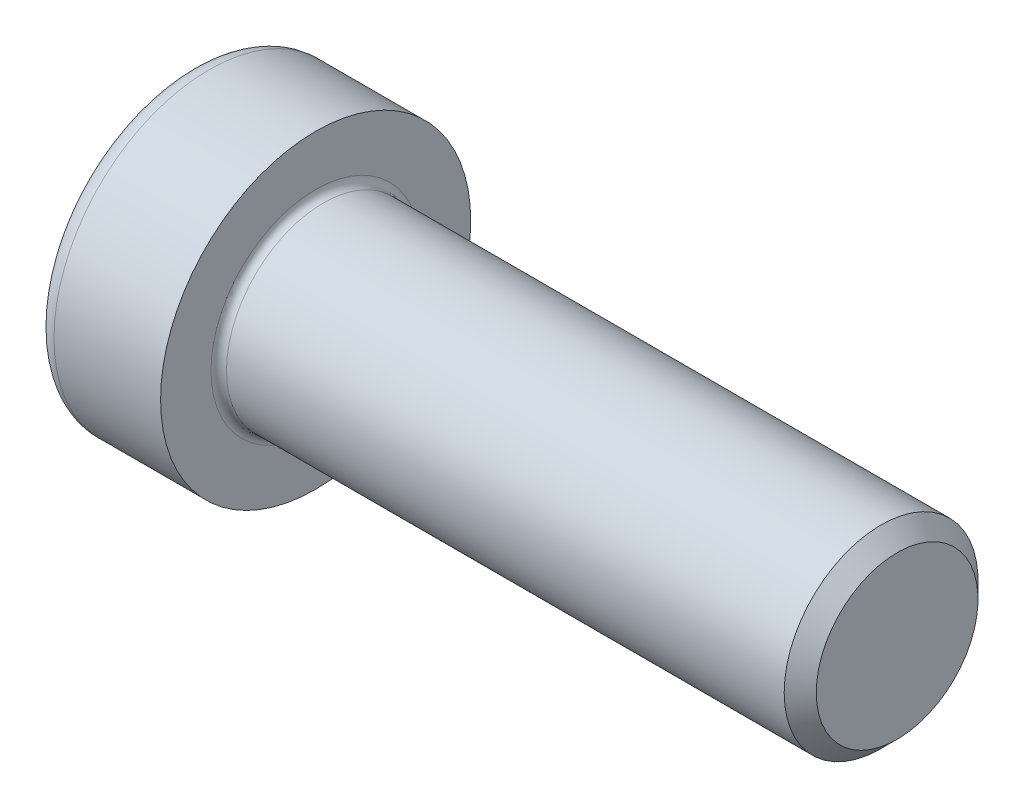
from build123d import *

# Parameters (mm, degrees)
FILLET1_R   = 0.4
FILLET2_R   = 1
HEX_2_DEPTH = 3.65


with BuildPart() as part:
    # BodySke → Base-Revolve (revolve)
    with BuildSketch(Plane.XY):
        Polygon((0, 0), (0, 8), (6.5, 8), (6.5, 5), (35.672, 5), (36.5, 4.172), (36.5, 0), align=None)
    revolve(axis=Axis((-31.75, 0, 0), (1, 0, 0)))

    # Fillet1
    fillet1_edges = [part.edges().sort_by_distance(p)[0] for p in [
        (6.5, -5, 0),
    ]]
    fillet(fillet1_edges, radius=FILLET1_R)

    # Fillet2
    fillet2_edges = [part.edges().sort_by_distance(p)[0] for p in [
        (0, -8, 0),
    ]]
    fillet(fillet2_edges, radius=FILLET2_R)

    # HexSke → Hex 2 (cut)
    with BuildSketch(Plane(origin=(0, 0, 0), x_dir=(0, 0.5, 0.866025404), z_dir=(-1, 0, 0))):
        Polygon((2.359919225, 4.0875), (-2.359919225, 4.0875), (-4.719838451, 0), (-2.359919225, -4.0875), (2.359919225, -4.0875), (4.719838451, 0), align=None)
    extrude(amount=-HEX_2_DEPTH, mode=Mode.SUBTRACT)

    # PilotSke → Hex-PreBroach (revolve, cut)
    with BuildSketch(Plane.XY):
        Polygon((0, 4.0875), (3.65, 4.0875), (4.544892917, 2.5375), (7.86, 2.5375), (9.325026308, 0), (0, 0), align=None)
    revolve(axis=Axis((0, 0, 0), (1, 0, 0)), mode=Mode.SUBTRACT)


solid = part.part
